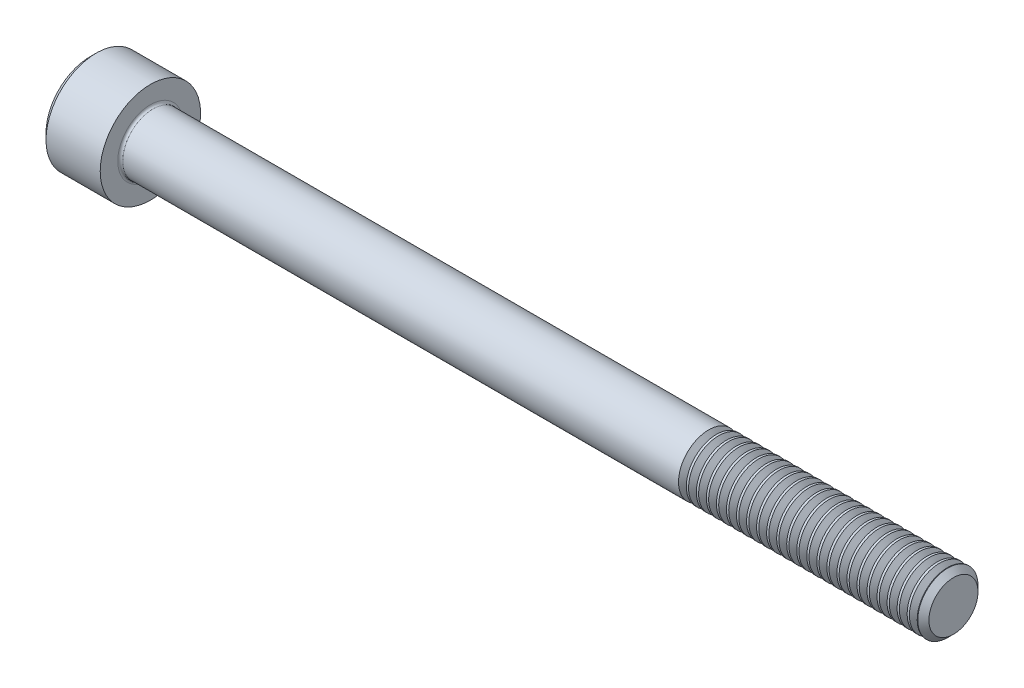
from build123d import *

# Parameters (mm, degrees)
FILLET1_R       = 0.25
HEX_2_DEPTH     = 3
THDSCHPAT_COUNT = 24
THDSCHPAT_PITCH = 1


with BuildPart() as part:
    # BodySke → Base-Revolve (revolve)
    with BuildSketch(Plane.XY):
        Polygon((0, 0), (0, 4.4), (0.6, 5), (6, 5), (6, 3), (85.4455, 3), (86, 2.4455), (86, 0), align=None)
    revolve(axis=Axis((-31.75, 0, 0), (1, 0, 0)))

    # Fillet1
    fillet1_edges = [part.edges().sort_by_distance(p)[0] for p in [
        (6, -3, 0),
    ]]
    fillet(fillet1_edges, radius=FILLET1_R)

    # Sketch2 → Hex-PreBroach (revolve, cut)
    with BuildSketch(Plane.XY):
        Polygon((0, 2.542), (3, 2.542), (4.467624384, 0), (0, 0), align=None)
    revolve(axis=Axis((0, 0, 0), (1, 0, 0)), mode=Mode.SUBTRACT)

    # Sketch3 → Hex 2 (cut)
    with BuildSketch(Plane(origin=(0, 0, 0), x_dir=(0, 0.5, 0.866025404), z_dir=(-1, 0, 0))):
        Polygon((1.467624384, 2.542), (-1.467624384, 2.542), (-2.935248769, 0), (-1.467624384, -2.542), (1.467624384, -2.542), (2.935248769, 0), align=None)
    extrude(amount=-HEX_2_DEPTH, mode=Mode.SUBTRACT)

    # ThdSchSke → ThreadSchematic (revolve, cut)
    with BuildSketch(Plane.XY):
        Polygon((62, -2.4455), (61.61173492, -3), (61.61173492, -3.75), (62.38826508, -3.75), (62.38826508, -3), align=None)
    threadschematic = revolve(axis=Axis((-3.175, 0, 0), (1, 0, 0)), mode=Mode.SUBTRACT)

    # ThdSchPat: ThreadSchematic ×24
    with Locations(*[(i * THDSCHPAT_PITCH, 0, 0) for i in range(1, THDSCHPAT_COUNT)]):
        add(threadschematic, mode=Mode.SUBTRACT)


solid = part.part
